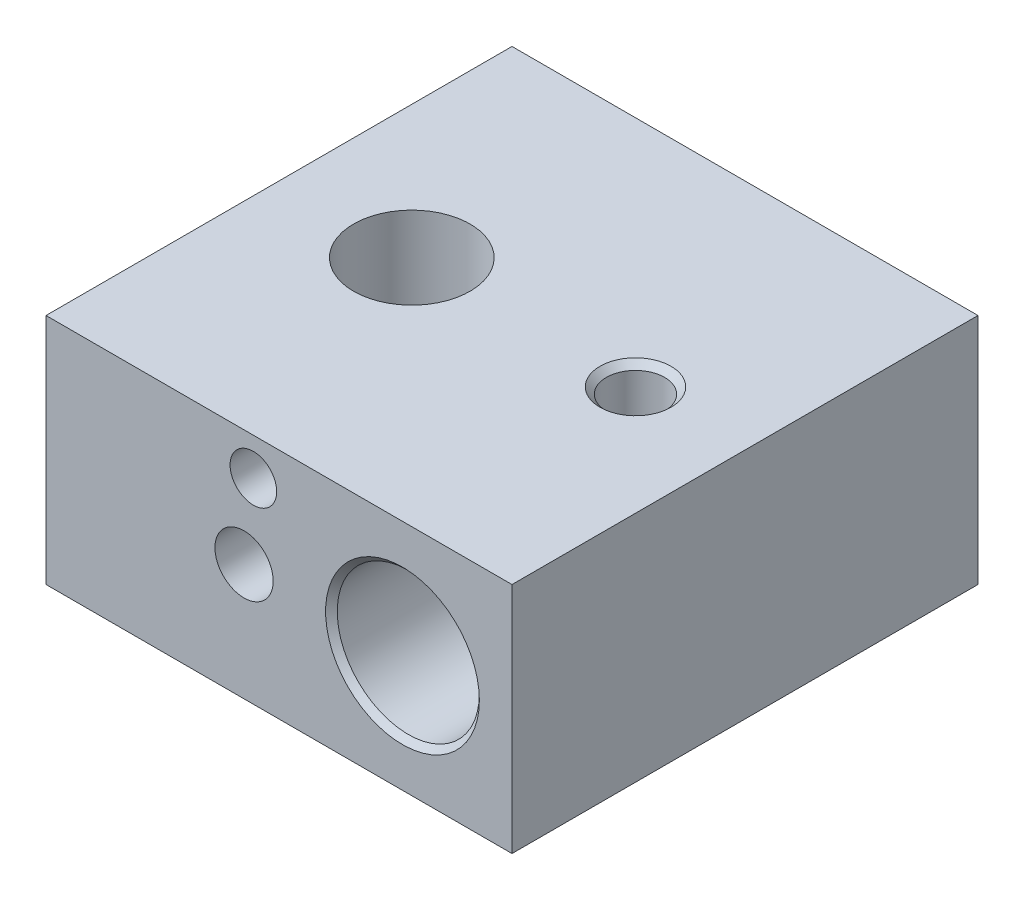
from build123d import *

# Parameters (mm, degrees)
SKETCH_1_W                   = 20
SKETCH_1_H                   = 20
EXTRUDE_1_DEPTH              = 10
HOLE_WIZARD_M3_2_D           = 2.5
HOLE_WIZARD_M3_2_DEPTH       = 5
HOLE_WIZARD_M3_2_TIP         = 0.751075774
HOLE_WIZARD_M3_3_D           = 2.5
HOLE_WIZARD_M3_3_DEPTH       = 6
HOLE_WIZARD_M3_3_CSINK_D     = 3.05
HOLE_WIZARD_M3_3_CSINK_ANGLE = 90
HOLE_WIZARD_M3_3_TIP         = 1.25
SKETCH_23_R                  = 2.5
CUT_EXTRUDE_1_DEPTH          = 11
SKETCH_40_R                  = 1
CUT_EXTRUDE_2_DEPTH          = 3


with BuildPart() as part:
    # 草图1 → 凸台-拉伸1 (new body)
    with BuildSketch(Plane(origin=(0, 0, 0), x_dir=(1, 0, 0), z_dir=(0, 1, 0))):
        Rectangle(SKETCH_1_W, SKETCH_1_H)
    extrude(amount=EXTRUDE_1_DEPTH)

    # 草图26 → Ø6.1 (6.1) 直径孔1 (revolve, cut)
    with BuildSketch(Plane(origin=(5.3, 5, 10), x_dir=(0, -1, 0), z_dir=(1, 0, 0))):
        Polygon((0, 0), (0, 20), (3.3, 20), (3.05, 19.75), (3.05, 0.25), (3.3, 0), align=None)
    revolve(axis=Axis((5.3, 5, 16.35), (0, 0, -1)), mode=Mode.SUBTRACT)

    # M3 螺纹孔2
    with Locations(Plane.XY.offset(10)):
        with Locations((-1.5, 5)):
            Hole(HOLE_WIZARD_M3_2_D / 2, depth=HOLE_WIZARD_M3_2_DEPTH)
            with Locations((0, 0, -(HOLE_WIZARD_M3_2_DEPTH + HOLE_WIZARD_M3_2_TIP / 2))):  # 118° drill point
                Cone(0, HOLE_WIZARD_M3_2_D / 2, HOLE_WIZARD_M3_2_TIP, mode=Mode.SUBTRACT)

    # M3 螺纹孔3
    with Locations(Plane(origin=(0, 10, 0), x_dir=(1, 0, 0), z_dir=(0, 1, 0))):
        with Locations((5.3, 0)):
            CounterSinkHole(HOLE_WIZARD_M3_3_D / 2, HOLE_WIZARD_M3_3_CSINK_D / 2, depth=HOLE_WIZARD_M3_3_DEPTH, counter_sink_angle=HOLE_WIZARD_M3_3_CSINK_ANGLE)
            with Locations((0, 0, -(HOLE_WIZARD_M3_3_DEPTH + HOLE_WIZARD_M3_3_TIP / 2))):  # 90° drill point
                Cone(0, HOLE_WIZARD_M3_3_D / 2, HOLE_WIZARD_M3_3_TIP, mode=Mode.SUBTRACT)

    # 草图23 → 切除-拉伸1 (cut, through all)
    with BuildSketch(Plane(origin=(0, 10, 0), x_dir=(1, 0, 0), z_dir=(0, 1, 0))):
        with Locations((-4.3, 0)):
            Circle(SKETCH_23_R)
    extrude(amount=-CUT_EXTRUDE_1_DEPTH, mode=Mode.SUBTRACT)

    # 草图40 → 切除-拉伸2 (cut)
    with BuildSketch(Plane.XY.offset(10)):
        with Locations((-1.1, 8.4)):
            Circle(SKETCH_40_R)
    extrude(amount=-CUT_EXTRUDE_2_DEPTH, mode=Mode.SUBTRACT)


solid = part.part
